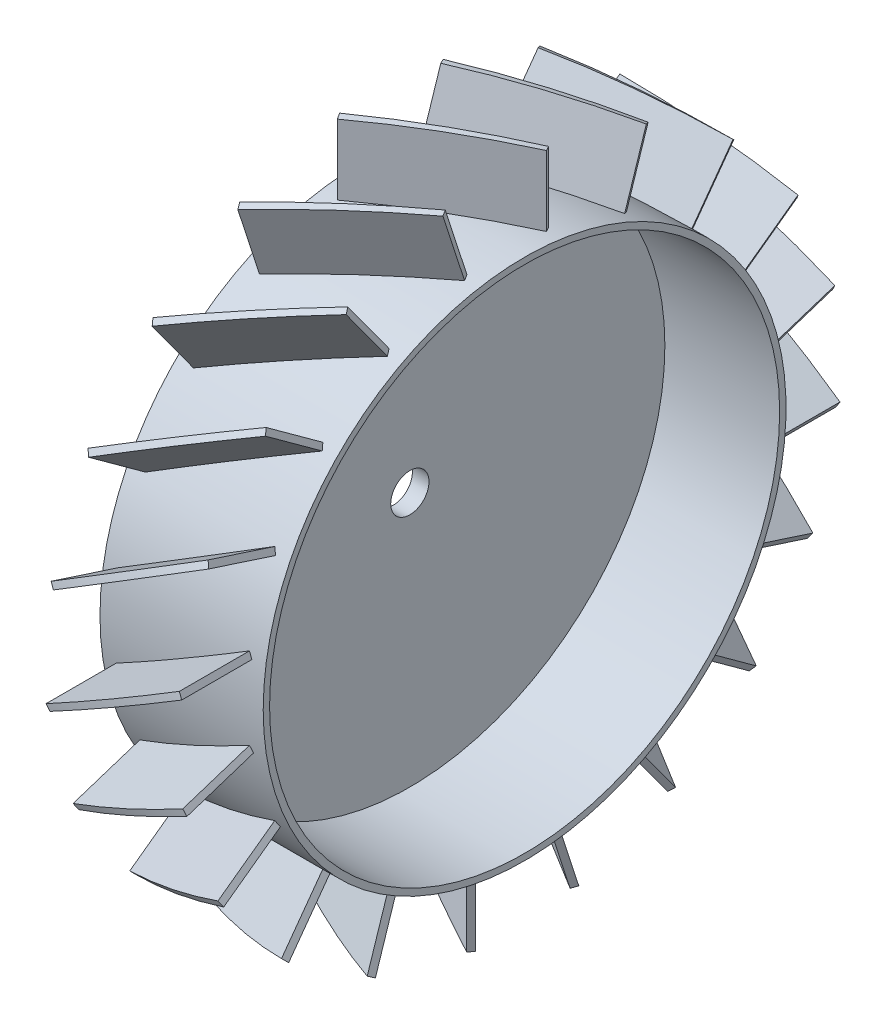
from build123d import *

# Parameters (mm, degrees)
BOSS_EXTRUDE1_REACH        = 163.827
BOSS_EXTRUDE1_START_RADIUS = 52.07
BOSS_EXTRUDE1_END_RADIUS   = 52.07
CIRPATTERN15_COUNT         = 20
SKETCH7_R                  = 3.81
CUT_EXTRUDE1_DEPTH         = 97.98975948


with BuildPart() as part:
    # Sketch1 → Revolve1 (revolve)
    with BuildSketch(Plane(origin=(0, 0, 0), x_dir=(1, 0, 0), z_dir=(0, 1, 0)), mode=Mode.PRIVATE) as revolve1_sk:
        Polygon((3.302, 0), (3.302, 50.8), (26.162, 50.8), (26.162, 52.07), (-6.35, 52.07), (-6.35, 50.8), (0, 50.8), (0, 0), align=None)
    revolve(revolve1_sk.sketch.rotate(Axis((0, 0, 0), (1, 0, 0)), 180), axis=Axis((0, 0, 0), (1, 0, 0)))

    # Boss-Extrude1: from a cylinder face, 163.827 long prism both ways, kept between that surface and its translate by the depth
    boss_extrude1_start = Plane(origin=(9.906, 0, 0), z_dir=(-1, 0, 0)) * Cylinder(BOSS_EXTRUDE1_START_RADIUS, 432.794, mode=Mode.PRIVATE)
    boss_extrude1_end = Plane(origin=(9.906, 0, 13.97), z_dir=(-1, 0, 0)) * Cylinder(BOSS_EXTRUDE1_END_RADIUS, 432.794, mode=Mode.PRIVATE)
    # Sketch2 → Boss-Extrude1 (add, from a surface)
    with BuildSketch(Plane.XY.offset(83.82), mode=Mode.PRIVATE) as boss_extrude1_sk1:
        Polygon((-2.974727154, -8.169926131), (23.421727154, 7.070073869), (22.786727154, 8.169926131), (-3.609727154, -7.070073869), align=None)
    boss_extrude1_tool1 = extrude(boss_extrude1_sk1.sketch, amount=BOSS_EXTRUDE1_REACH, both=True, mode=Mode.PRIVATE)
    boss_extrude1 = ((boss_extrude1_tool1 - boss_extrude1_start) & boss_extrude1_end).solids().sort_by_distance((9.906, 0, 58.491422))[0]
    add(boss_extrude1)

    # CirPattern15: Boss-Extrude1 ×20 about axis
    cirpattern15_axis = Axis((0, 0, 0), (1, 0, 0))
    for i in range(1, CIRPATTERN15_COUNT):
        add(boss_extrude1.rotate(cirpattern15_axis, i * 360 / CIRPATTERN15_COUNT))

    # Sketch7 → Cut-Extrude1 (cut, through all)
    with BuildSketch(Plane.ZY):
        Circle(SKETCH7_R)
    extrude(amount=-CUT_EXTRUDE1_DEPTH, mode=Mode.SUBTRACT)


solid = part.part
